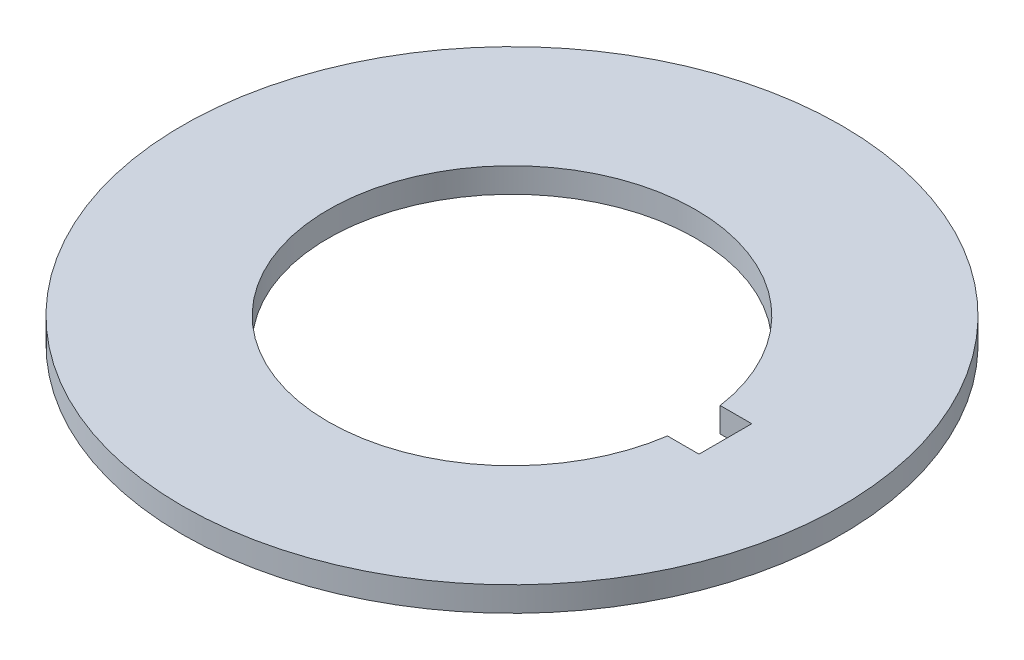
from build123d import *

# Parameters (mm, degrees)
SKETCH1_R           = 20
BOSS_EXTRUDE1_DEPTH = 1.5


with BuildPart() as part:
    # Sketch1 → Boss-Extrude1 (new body)
    with BuildSketch(Plane(origin=(0, 0, 0), x_dir=(1, 0, 0), z_dir=(0, 1, 0))):
        Circle(SKETCH1_R)
        with BuildLine():
            Line((11.03460466, 1.6), (12.95, 1.6))
            Line((12.95, 1.6), (12.95, -1.6))
            Line((12.95, -1.6), (11.03460466, -1.6))
            ThreePointArc((11.03460466, -1.6), (-11.15, 0), (11.03460466, 1.6))
        make_face(mode=Mode.SUBTRACT)
    extrude(amount=BOSS_EXTRUDE1_DEPTH)


solid = part.part
